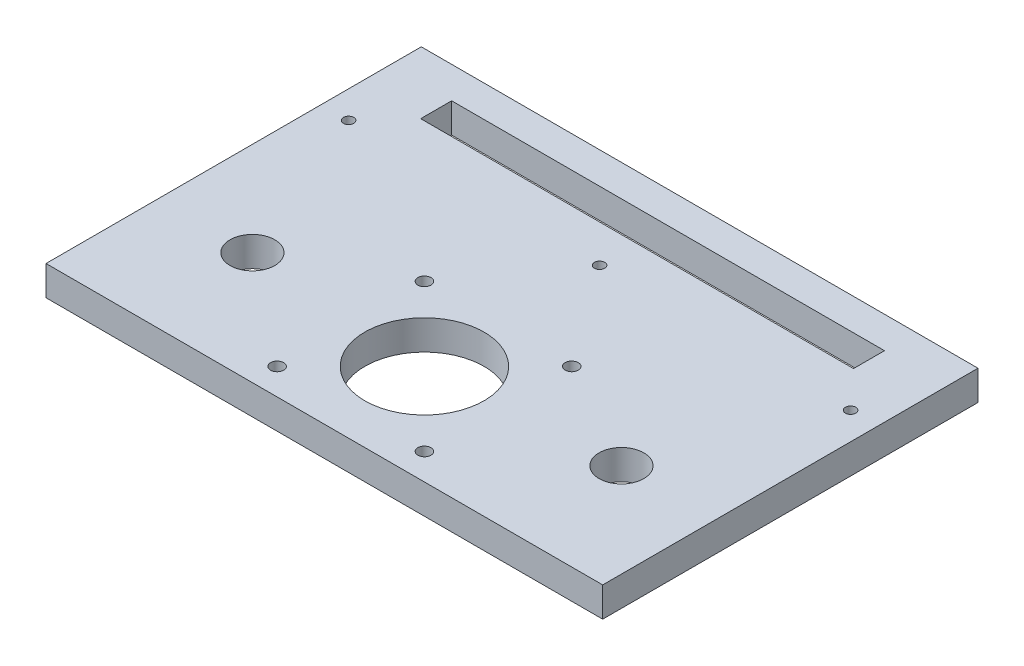
from build123d import *

# Parameters (mm, degrees)
SKETCH1_W           = 178
SKETCH1_H           = 120
SKETCH1_R           = 19.05
SKETCH1_R_2         = 7.15
SKETCH1_W_2         = 138.4
SKETCH1_H_2         = 9.9
BOSS_EXTRUDE1_DEPTH = 9.5
M4_TAPPED_HOLE1_D   = 3.3
M5_TAPPED_HOLE1_D   = 4.2


with BuildPart() as part:
    # Sketch1 → Boss-Extrude1 (new body)
    with BuildSketch(Plane(origin=(0, 0, 0), x_dir=(1, 0, 0), z_dir=(0, 1, 0))):
        Rectangle(SKETCH1_W, SKETCH1_H)
        with Locations((0, -28)):
            Circle(SKETCH1_R, mode=Mode.SUBTRACT)
        with Locations((-59, -24)):
            Circle(SKETCH1_R_2, mode=Mode.SUBTRACT)
        with Locations((59, -24)):
            Circle(SKETCH1_R_2, mode=Mode.SUBTRACT)
        with Locations((0, 44.95)):
            Rectangle(SKETCH1_W_2, SKETCH1_H_2, mode=Mode.SUBTRACT)
    extrude(amount=BOSS_EXTRUDE1_DEPTH)

    # M4 Tapped Hole1 (through all)
    with Locations(Plane(origin=(0, 9.5, 0), x_dir=(1, 0, 0), z_dir=(0, 1, 0))):
        with Locations((-80.25, 28), (0, 28), (80.25, 28)):
            Hole(M4_TAPPED_HOLE1_D / 2)

    # M5 Tapped Hole1 (through all)
    with Locations(Plane(origin=(0, 9.5, 0), x_dir=(1, 0, 0), z_dir=(0, 1, 0))):
        with Locations((-23.55, -4.45), (23.55, -4.45), (23.55, -51.55), (-23.55, -51.55)):
            Hole(M5_TAPPED_HOLE1_D / 2)


solid = part.part
